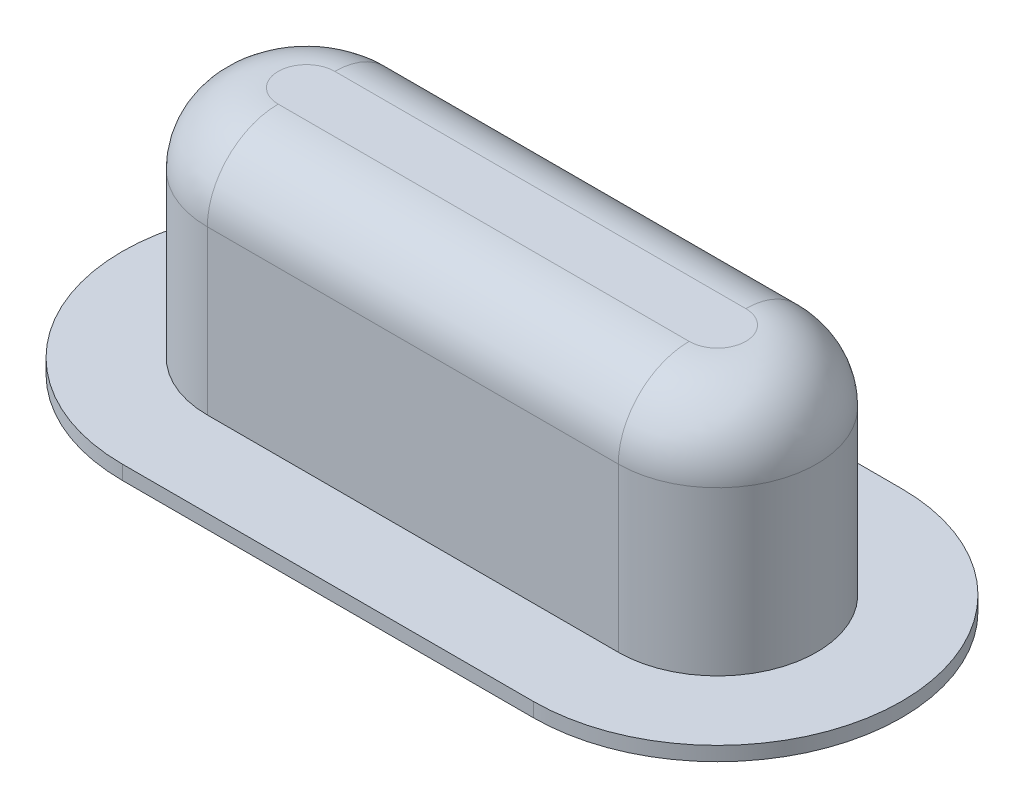
from build123d import *

# Parameters (mm, degrees)
BOSS_EXTRUDE1_DEPTH = 35
FILLET1_R           = 10
SHELL1_T            = -4
BOSS_EXTRUDE2_DEPTH = 2


with BuildPart() as part:
    # Sketch2 → Boss-Extrude1 (new body)
    with BuildSketch(Plane(origin=(0, 0, 0), x_dir=(1, 0, 0), z_dir=(0, 1, 0))):
        with BuildLine():
            Line((-29, 14), (29, 14))
            ThreePointArc((29, 14), (43, 0), (29, -14))
            Line((29, -14), (-29, -14))
            ThreePointArc((-29, -14), (-43, 0), (-29, 14))
        make_face()
    extrude(amount=BOSS_EXTRUDE1_DEPTH)

    # Fillet1
    fillet1_edges = [part.edges().sort_by_distance(p)[0] for p in [
        (43, 35, 0),
        (0, 35, -14),
        (-43, 35, 0),
        (0, 35, 14),
    ]]
    fillet(fillet1_edges, radius=FILLET1_R)

    # Shell1
    shell1_openings = [part.faces().sort_by_distance(p)[0] for p in [
        (0, 0, 0),
    ]]
    offset(amount=SHELL1_T, openings=shell1_openings, kind=Kind.INTERSECTION)

    # Sketch3 → Boss-Extrude2 (add)
    with BuildSketch(Plane.XZ):
        with BuildLine():
            Line((-29, -26), (29, -26))
            ThreePointArc((29, -26), (55, 0), (29, 26))
            Line((29, 26), (-29, 26))
            ThreePointArc((-29, 26), (-55, 0), (-29, -26))
        make_face()
        with BuildLine():
            Line((-29, -10), (29, -10))
            ThreePointArc((29, -10), (39, 0), (29, 10))
            Line((29, 10), (-29, 10))
            ThreePointArc((-29, 10), (-39, 0), (-29, -10))
        make_face(mode=Mode.SUBTRACT)
    extrude(amount=-BOSS_EXTRUDE2_DEPTH)


solid = part.part
